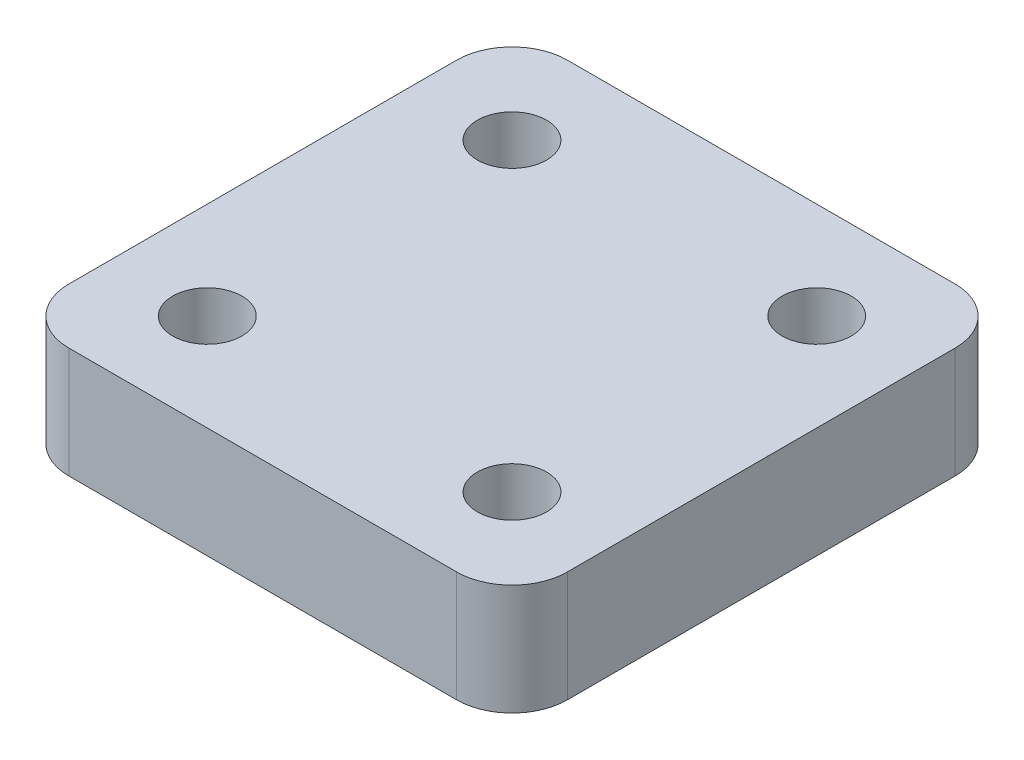
from build123d import *

# Parameters (mm, degrees)
IZIM1_R                     = 125
Y_KSEKLIK_EKSTR_ZYON2_DEPTH = 400
IZIM2_R                     = 530
KES_EKSTR_ZYON1_DEPTH       = 150
IZIM3_R                     = 540
Y_KSEKLIK_EKSTR_ZYON3_DEPTH = 300


with BuildPart() as part:
    # Çizim1 → Yükseklik-Ekstrüzyon2 (new body)
    with BuildSketch(Plane(origin=(0, 0, 0), x_dir=(1, 0, 0), z_dir=(0, 1, 0))):
        with BuildLine():
            Line((-900, 700), (-900, -700))
            ThreePointArc((-900, -700), (-841.421356237, -841.421356237), (-700, -900))
            Line((-700, -900), (700, -900))
            ThreePointArc((700, -900), (841.421356237, -841.421356237), (900, -700))
            Line((900, -700), (900, 700))
            ThreePointArc((900, 700), (841.421356237, 841.421356237), (700, 900))
            Line((700, 900), (-700, 900))
            ThreePointArc((-700, 900), (-841.421356237, 841.421356237), (-900, 700))
        make_face()
        with Locations((-550, 550)):
            Circle(IZIM1_R, mode=Mode.SUBTRACT)
        with Locations((550, 550)):
            Circle(IZIM1_R, mode=Mode.SUBTRACT)
        with Locations((-550, -550)):
            Circle(IZIM1_R, mode=Mode.SUBTRACT)
        with Locations((550, -550)):
            Circle(IZIM1_R, mode=Mode.SUBTRACT)
    extrude(amount=Y_KSEKLIK_EKSTR_ZYON2_DEPTH)

    # Çizim2 → Kes-Ekstrüzyon1 (cut)
    with BuildSketch(Plane.XZ):
        Circle(IZIM2_R)
    extrude(amount=-KES_EKSTR_ZYON1_DEPTH, mode=Mode.SUBTRACT)

    # Çizim3 → Yükseklik-Ekstrüzyon3 (add)
    with BuildSketch(Plane.XZ.offset(-150)):
        Circle(IZIM3_R)
    extrude(amount=Y_KSEKLIK_EKSTR_ZYON3_DEPTH)


solid = part.part
